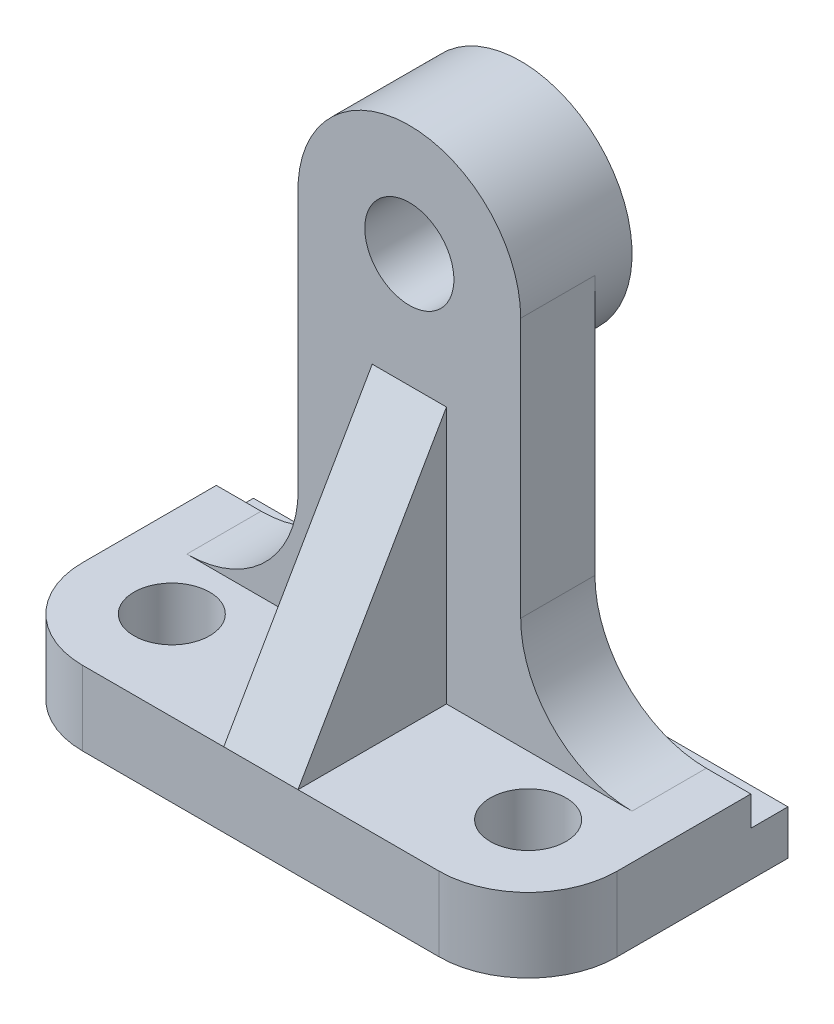
from build123d import *

# Parameters (mm, degrees)
SKETCH1_W           = 72
SKETCH1_H           = 35
BOSS_EXTRUDE1_DEPTH = 10
FILLET1_R           = 12
SKETCH3_W           = 5
SKETCH3_H           = 4
CUT_EXTRUDE1_DEPTH  = 89
SKETCH6_R           = 6
BOSS_EXTRUDE2_DEPTH = 10
FILLET2_R           = 15
M12_TAPPED_HOLE1_D  = 10.2
SKETCH11_R          = 15
BOSS_EXTRUDE5_DEPTH = 5
SKETCH18_R          = 6
CUT_EXTRUDE2_DEPTH  = 91.255193756
RIB1_REACH          = 87.013
SKETCH19_WALL_W     = 212.026468528
SKETCH19_WALL_H     = 10


with BuildPart() as part:
    # Sketch1 → Boss-Extrude1 (new body)
    with BuildSketch(Plane(origin=(0, 0, 0), x_dir=(1, 0, 0), z_dir=(0, 1, 0))):
        Rectangle(SKETCH1_W, SKETCH1_H)
    extrude(amount=BOSS_EXTRUDE1_DEPTH)

    # Fillet1
    fillet1_edges = [part.edges().sort_by_distance(p)[0] for p in [
        (36, 5, 17.5),
        (-36, 5, 17.5),
    ]]
    fillet(fillet1_edges, radius=FILLET1_R)

    # Sketch3 → Cut-Extrude1 (cut)
    with BuildSketch(Plane(origin=(36, 0, 0), x_dir=(0, 0, -1), z_dir=(1, 0, 0))):
        with Locations((15, 8)):
            Rectangle(SKETCH3_W, SKETCH3_H)
    extrude(amount=-CUT_EXTRUDE1_DEPTH, mode=Mode.SUBTRACT)

    # Sketch6 → Boss-Extrude2 (add)
    with BuildSketch(Plane(origin=(0, 0, -12.5), x_dir=(-1, 0, 0), z_dir=(0, 0, -1))):
        with BuildLine():
            Line((14.970991041, 10), (-15, 10))
            Line((-15, 10), (-15, 60))
            ThreePointArc((-15, 60), (-0.466440987, 74.992746006), (14.970991041, 60.932430832))
            Line((14.970991041, 60.932430832), (14.970991041, 10))
        make_face()
        with Locations((0, 60)):
            Circle(SKETCH6_R, mode=Mode.SUBTRACT)
    extrude(amount=-BOSS_EXTRUDE2_DEPTH)

    # Fillet2
    fillet2_edges = [part.edges().sort_by_distance(p)[0] for p in [
        (-14.970991041, 10, -7.5),
        (15, 10, -7.5),
    ]]
    fillet(fillet2_edges, radius=FILLET2_R)

    # M12 Tapped Hole1 (through all)
    with Locations(Plane(origin=(0, 10, 0), x_dir=(1, 0, 0), z_dir=(0, 1, 0))):
        with Locations((24, -5.5), (-24, -5.5)):
            Hole(M12_TAPPED_HOLE1_D / 2)

    # Sketch11 → Boss-Extrude5 (add)
    with BuildSketch(Plane(origin=(0, 0, -12.5), x_dir=(-1, 0, 0), z_dir=(0, 0, -1))):
        with Locations((0, 60)):
            Circle(SKETCH11_R)
    extrude(amount=BOSS_EXTRUDE5_DEPTH)

    # Sketch18 → Cut-Extrude2 (cut, through all)
    with BuildSketch(Plane(origin=(0, 0, -17.5), x_dir=(-1, 0, 0), z_dir=(0, 0, -1))):
        with Locations((0, 60)):
            Circle(SKETCH18_R)
    extrude(amount=-CUT_EXTRUDE2_DEPTH, mode=Mode.SUBTRACT)

    # Sketch19 wall → Rib1 (add, up to next)
    with BuildSketch(Plane(origin=(0, 27.320508076, 7.5), x_dir=(0, 0.866025403782, -0.500000000004), z_dir=(0, 0.500000000004, 0.866025403782)), mode=Mode.PRIVATE) as rib1_sk1:
        Rectangle(SKETCH19_WALL_W, SKETCH19_WALL_H)
    rib1_tool1 = extrude(rib1_sk1.sketch, amount=-RIB1_REACH, mode=Mode.PRIVATE) - part.part
    add(rib1_tool1.solids().sort_by_distance((0, 27.320508076, 7.5))[0])


solid = part.part
